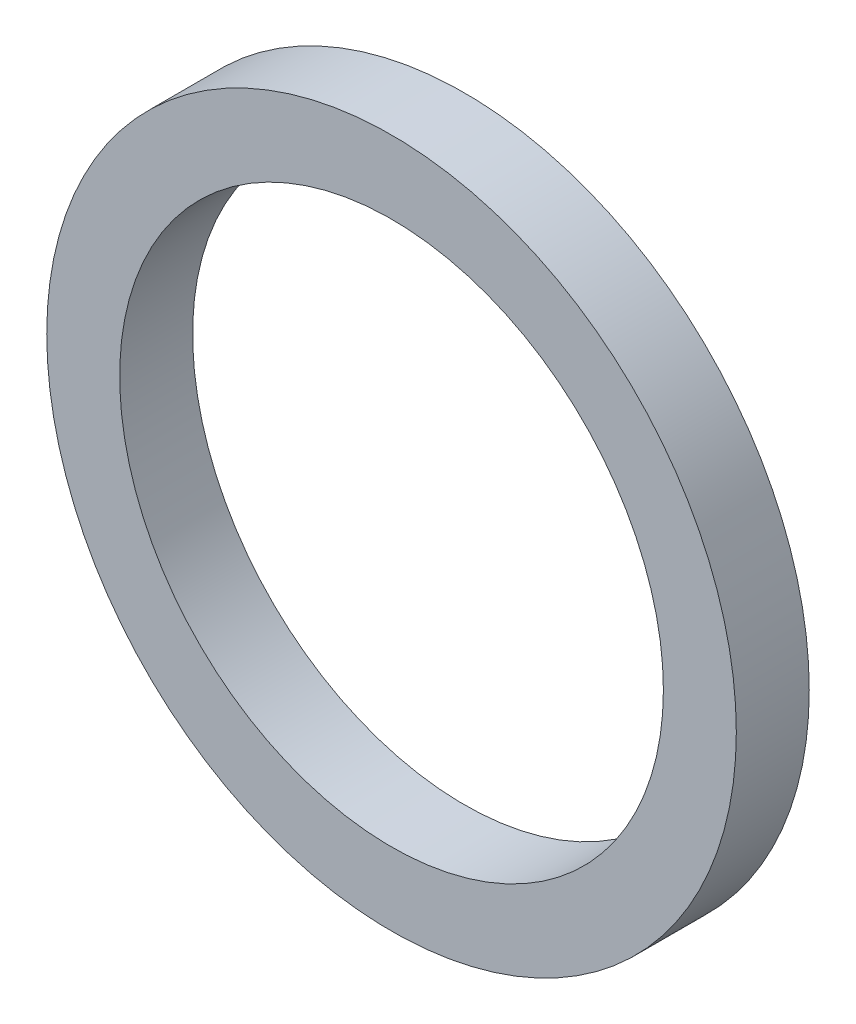
from build123d import *

# Parameters (mm, degrees)
SKETCH1_R           = 5.2
SKETCH1_R_2         = 4.1
BOSS_EXTRUDE1_DEPTH = 1.1


with BuildPart() as part:
    # Sketch1 → Boss-Extrude1 (new body)
    with BuildSketch(Plane.XY):
        Circle(SKETCH1_R)
        Circle(SKETCH1_R_2, mode=Mode.SUBTRACT)
    extrude(amount=BOSS_EXTRUDE1_DEPTH)


solid = part.part
